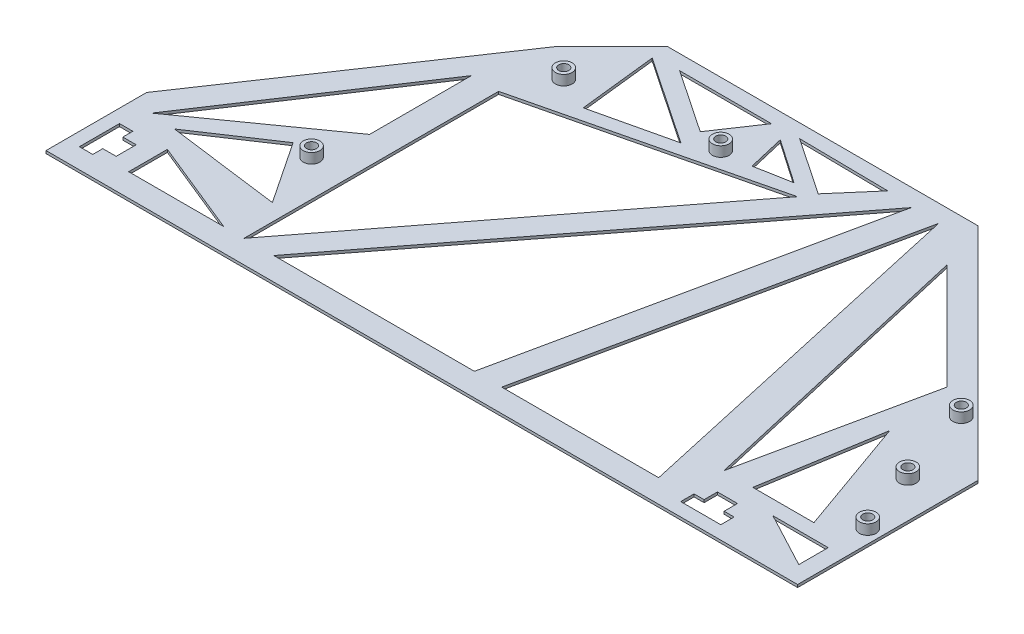
from build123d import *

# Parameters (mm, degrees)
SKETCH2_R                 = 2.5
BOSS_EXTRUDE1_DEPTH       = 3
BOSS_EXTRUDE1_2_DEPTH     = 3
BOSS_EXTRUDE1_3_DEPTH     = 3
BOSS_EXTRUDE1_4_DEPTH     = 3
BOSS_EXTRUDE1_5_DEPTH     = 3
BOSS_EXTRUDE1_6_DEPTH     = 3
SKETCH4_W                 = 225
SKETCH4_H                 = 120
BOSS_EXTRUDE2_DEPTH       = 0.8
F_3_0MM_DOWEL_HOLE1_D     = 3
F_3_0MM_DOWEL_HOLE1_DEPTH = 4
CUT_EXTRUDE1_REACH        = 2.8
CHAMFER1_SIZE             = 66
CUT_EXTRUDE2_REACH        = 2.8
CHAMFER3_SIZE             = 70
CHAMFER3_SIZE2            = 23.885549322


with BuildPart() as part:
    # Sketch2 → Boss-Extrude1 (new body)
    with BuildSketch(Plane(origin=(0, 0, 0), x_dir=(1, 0, 0), z_dir=(0, 1, 0))):
        with Locations((101, 101)):
            Circle(SKETCH2_R)
    extrude(amount=BOSS_EXTRUDE1_DEPTH)



with BuildPart() as body_2:
    # Sketch2 → Boss-Extrude1 2 (new body)
    with BuildSketch(Plane(origin=(0, 0, 0), x_dir=(1, 0, 0), z_dir=(0, 1, 0))):
        with Locations((206, 68)):
            Circle(SKETCH2_R)
    extrude(amount=BOSS_EXTRUDE1_2_DEPTH)


with BuildPart() as body_3:
    # Sketch2 → Boss-Extrude1 3 (new body)
    with BuildSketch(Plane(origin=(0, 0, 0), x_dir=(1, 0, 0), z_dir=(0, 1, 0))):
        with Locations((214, 44)):
            Circle(SKETCH2_R)
    extrude(amount=BOSS_EXTRUDE1_3_DEPTH)


with BuildPart() as body_4:
    # Sketch2 → Boss-Extrude1 4 (new body)
    with BuildSketch(Plane(origin=(0, 0, 0), x_dir=(1, 0, 0), z_dir=(0, 1, 0))):
        with Locations((221, 25)):
            Circle(SKETCH2_R)
    extrude(amount=BOSS_EXTRUDE1_4_DEPTH)


with BuildPart() as body_5:
    # Sketch2 → Boss-Extrude1 5 (new body)
    with BuildSketch(Plane(origin=(0, 0, 0), x_dir=(1, 0, 0), z_dir=(0, 1, 0))):
        with Locations((41.5, 38)):
            Circle(SKETCH2_R)
    extrude(amount=BOSS_EXTRUDE1_5_DEPTH)


with BuildPart() as body_6:
    # Sketch2 → Boss-Extrude1 6 (new body)
    with BuildSketch(Plane(origin=(0, 0, 0), x_dir=(1, 0, 0), z_dir=(0, 1, 0))):
        with Locations((59, 96)):
            Circle(SKETCH2_R)
    extrude(amount=BOSS_EXTRUDE1_6_DEPTH)


with BuildPart() as part_1:
    add(part.part)

    add(body_2.part)  # Boss-Extrude2 merges body 2

    add(body_3.part)  # Boss-Extrude2 merges body 3

    add(body_4.part)  # Boss-Extrude2 merges body 4

    add(body_5.part)  # Boss-Extrude2 merges body 5

    add(body_6.part)  # Boss-Extrude2 merges body 6
    # Sketch4 → Boss-Extrude2 (add)
    with BuildSketch(Plane(origin=(0, 0, 0), x_dir=(1, 0, 0), z_dir=(0, 1, 0))):
        with Locations((112.5, 60)):
            Rectangle(SKETCH4_W, SKETCH4_H)
    extrude(amount=-BOSS_EXTRUDE2_DEPTH)

    # Ø3.0mm Dowel Hole1
    with Locations(Plane(origin=(0, 3, 0), x_dir=(1, 0, 0), z_dir=(0, 1, 0))):
        with Locations((59, 96), (101, 101), (206, 68), (214, 44), (221, 25), (41.5, 38)):
            Hole(F_3_0MM_DOWEL_HOLE1_D / 2, depth=F_3_0MM_DOWEL_HOLE1_DEPTH)

    # Sketch27 → Cut-Extrude1 (cut, up to next)
    with BuildSketch(Plane(origin=(0, 0, 0), x_dir=(1, 0, 0), z_dir=(0, 1, 0)), mode=Mode.PRIVATE) as cut_extrude1_sk1:
        Polygon((186, 8), (189, 8), (189, 12), (195, 12), (195, 8), (198, 8), (198, 4), (186, 4), align=None)
    cut_extrude1_tool1 = extrude(cut_extrude1_sk1.sketch, amount=-CUT_EXTRUDE1_REACH, mode=Mode.PRIVATE) & part_1.part
    add(cut_extrude1_tool1.solids().sort_by_distance((192, 0, -7.333333))[0], mode=Mode.SUBTRACT)
    # Sketch27 → Cut-Extrude1 (cut, up to next)
    with BuildSketch(Plane(origin=(0, 0, 0), x_dir=(1, 0, 0), z_dir=(0, 1, 0)), mode=Mode.PRIVATE) as cut_extrude1_sk2:
        Polygon((4, 6), (8, 6), (8, 9), (12, 9), (12, 15), (8, 15), (8, 18), (4, 18), align=None)
    cut_extrude1_tool2 = extrude(cut_extrude1_sk2.sketch, amount=-CUT_EXTRUDE1_REACH, mode=Mode.PRIVATE) & part_1.part
    add(cut_extrude1_tool2.solids().sort_by_distance((7.333333, 0, -12))[0], mode=Mode.SUBTRACT)

    # Chamfer1
    chamfer1_edges = [part_1.edges().sort_by_distance(p)[0] for p in [
        (0, -0.4, -120),
        (225, -0.4, -120),
    ]]
    chamfer(chamfer1_edges, length=CHAMFER1_SIZE)

    # Sketch28 → Cut-Extrude2 (cut, up to next)
    with BuildSketch(Plane(origin=(0, 0, 0), x_dir=(1, 0, 0), z_dir=(0, 1, 0)), mode=Mode.PRIVATE) as cut_extrude2_sk1:
        Polygon((52.388319297, 6.891877983), (52.388319297, 83.093591857), (124.427979621, 100.514856146), align=None)
    cut_extrude2_tool1 = extrude(cut_extrude2_sk1.sketch, amount=-CUT_EXTRUDE2_REACH, mode=Mode.PRIVATE) & part_1.part
    add(cut_extrude2_tool1.solids().sort_by_distance((76.401539, 0, -63.500109))[0], mode=Mode.SUBTRACT)
    # Sketch28 → Cut-Extrude2 (cut, up to next)
    with BuildSketch(Plane(origin=(0, 0, 0), x_dir=(1, 0, 0), z_dir=(0, 1, 0)), mode=Mode.PRIVATE) as cut_extrude2_sk2:
        Polygon((144.286671327, 114.724380441), (61.313270979, 6.891877983), (121.338711512, 6.891877983), align=None)
    cut_extrude2_tool2 = extrude(cut_extrude2_sk2.sketch, amount=-CUT_EXTRUDE2_REACH, mode=Mode.PRIVATE) & part_1.part
    add(cut_extrude2_tool2.solids().sort_by_distance((108.979551, 0, -42.836045))[0], mode=Mode.SUBTRACT)
    # Sketch28 → Cut-Extrude2 (cut, up to next)
    with BuildSketch(Plane(origin=(0, 0, 0), x_dir=(1, 0, 0), z_dir=(0, 1, 0)), mode=Mode.PRIVATE) as cut_extrude2_sk3:
        Polygon((152.485832321, 114.724380441), (129.537872506, 6.891877983), (176.515283586, 6.891877983), align=None)
    cut_extrude2_tool3 = extrude(cut_extrude2_sk3.sketch, amount=-CUT_EXTRUDE2_REACH, mode=Mode.PRIVATE) & part_1.part
    add(cut_extrude2_tool3.solids().sort_by_distance((152.846329, 0, -42.836045))[0], mode=Mode.SUBTRACT)
    # Sketch28 → Cut-Extrude2 (cut, up to next)
    with BuildSketch(Plane(origin=(0, 0, 0), x_dir=(1, 0, 0), z_dir=(0, 1, 0)), mode=Mode.PRIVATE) as cut_extrude2_sk4:
        Polygon((164.500557953, 105.19569086), (196.171947419, 73.524301395), (184.457582932, 18.478482617), align=None)
    cut_extrude2_tool4 = extrude(cut_extrude2_sk4.sketch, amount=-CUT_EXTRUDE2_REACH, mode=Mode.PRIVATE) & part_1.part
    add(cut_extrude2_tool4.solids().sort_by_distance((181.710029, 0, -65.732825))[0], mode=Mode.SUBTRACT)
    # Sketch28 → Cut-Extrude2 (cut, up to next)
    with BuildSketch(Plane(origin=(0, 0, 0), x_dir=(1, 0, 0), z_dir=(0, 1, 0)), mode=Mode.PRIVATE) as cut_extrude2_sk5:
        Polygon((198.888278472, 53.703367065), (211.405882256, 18.478482617), (193.110922879, 18.478482617), align=None)
    cut_extrude2_tool5 = extrude(cut_extrude2_sk5.sketch, amount=-CUT_EXTRUDE2_REACH, mode=Mode.PRIVATE) & part_1.part
    add(cut_extrude2_tool5.solids().sort_by_distance((201.135028, 0, -30.220111))[0], mode=Mode.SUBTRACT)
    # Sketch28 → Cut-Extrude2 (cut, up to next)
    with BuildSketch(Plane(origin=(0, 0, 0), x_dir=(1, 0, 0), z_dir=(0, 1, 0)), mode=Mode.PRIVATE) as cut_extrude2_sk6:
        Polygon((44.242680865, 83.093591857), (44.242680865, 52.616095827), (6.082421341, 25.506148765), align=None)
    cut_extrude2_tool6 = extrude(cut_extrude2_sk6.sketch, amount=-CUT_EXTRUDE2_REACH, mode=Mode.PRIVATE) & part_1.part
    add(cut_extrude2_tool6.solids().sort_by_distance((31.522594, 0, -53.738612))[0], mode=Mode.SUBTRACT)
    # Sketch28 → Cut-Extrude2 (cut, up to next)
    with BuildSketch(Plane(origin=(0, 0, 0), x_dir=(1, 0, 0), z_dir=(0, 1, 0)), mode=Mode.PRIVATE) as cut_extrude2_sk7:
        Polygon((13.630560586, 24.81954669), (34.944244067, 39.030171699), (47.359604213, 20.409100754), align=None)
    cut_extrude2_tool7 = extrude(cut_extrude2_sk7.sketch, amount=-CUT_EXTRUDE2_REACH, mode=Mode.PRIVATE) & part_1.part
    add(cut_extrude2_tool7.solids().sort_by_distance((31.978136, 0, -28.086273))[0], mode=Mode.SUBTRACT)
    # Sketch28 → Cut-Extrude2 (cut, up to next)
    with BuildSketch(Plane(origin=(0, 0, 0), x_dir=(1, 0, 0), z_dir=(0, 1, 0)), mode=Mode.PRIVATE) as cut_extrude2_sk8:
        Polygon((17.858383702, 18.478482617), (17.858383702, 6.891877983), (46.339021234, 6.891877983), align=None)
    cut_extrude2_tool8 = extrude(cut_extrude2_sk8.sketch, amount=-CUT_EXTRUDE2_REACH, mode=Mode.PRIVATE) & part_1.part
    add(cut_extrude2_tool8.solids().sort_by_distance((27.35193, 0, -10.75408))[0], mode=Mode.SUBTRACT)
    # Sketch28 → Cut-Extrude2 (cut, up to next)
    with BuildSketch(Plane(origin=(0, 0, 0), x_dir=(1, 0, 0), z_dir=(0, 1, 0)), mode=Mode.PRIVATE) as cut_extrude2_sk9:
        Polygon((66.741601703, 114.724380441), (69.339310273, 91.487471585), (93.043400976, 97.007602296), align=None)
    cut_extrude2_tool9 = extrude(cut_extrude2_sk9.sketch, amount=-CUT_EXTRUDE2_REACH, mode=Mode.PRIVATE) & part_1.part
    add(cut_extrude2_tool9.solids().sort_by_distance((76.374771, 0, -101.073151))[0], mode=Mode.SUBTRACT)
    # Sketch28 → Cut-Extrude2 (cut, up to next)
    with BuildSketch(Plane(origin=(0, 0, 0), x_dir=(1, 0, 0), z_dir=(0, 1, 0)), mode=Mode.PRIVATE) as cut_extrude2_sk10:
        Polygon((74.134214928, 115.550818021), (93.043400976, 102.813672146), (101.623087305, 115.550818021), align=None)
    cut_extrude2_tool10 = extrude(cut_extrude2_sk10.sketch, amount=-CUT_EXTRUDE2_REACH, mode=Mode.PRIVATE) & part_1.part
    add(cut_extrude2_tool10.solids().sort_by_distance((89.600234, 0, -111.305103))[0], mode=Mode.SUBTRACT)
    # Sketch28 → Cut-Extrude2 (cut, up to next)
    with BuildSketch(Plane(origin=(0, 0, 0), x_dir=(1, 0, 0), z_dir=(0, 1, 0)), mode=Mode.PRIVATE) as cut_extrude2_sk11:
        Polygon((136.446781668, 115.550818021), (126.813612387, 104.367776578), (109.710747348, 115.88819244), align=None)
    cut_extrude2_tool11 = extrude(cut_extrude2_sk11.sketch, amount=-CUT_EXTRUDE2_REACH, mode=Mode.PRIVATE) & part_1.part
    add(cut_extrude2_tool11.solids().sort_by_distance((124.323714, 0, -111.935596))[0], mode=Mode.SUBTRACT)
    # Sketch28 → Cut-Extrude2 (cut, up to next)
    with BuildSketch(Plane(origin=(0, 0, 0), x_dir=(1, 0, 0), z_dir=(0, 1, 0)), mode=Mode.PRIVATE) as cut_extrude2_sk12:
        Polygon((107.114322397, 112.702091574), (120.319340962, 103.610111579), (109.710747348, 101.653186543), align=None)
    cut_extrude2_tool12 = extrude(cut_extrude2_sk12.sketch, amount=-CUT_EXTRUDE2_REACH, mode=Mode.PRIVATE) & part_1.part
    add(cut_extrude2_tool12.solids().sort_by_distance((112.38147, 0, -105.988463))[0], mode=Mode.SUBTRACT)
    # Sketch28 → Cut-Extrude2 (cut, up to next)
    with BuildSketch(Plane(origin=(0, 0, 0), x_dir=(1, 0, 0), z_dir=(0, 1, 0)), mode=Mode.PRIVATE) as cut_extrude2_sk13:
        Polygon((203.456645773, 14.141546381), (220.018577109, 14.141546381), (220.018577109, 5.336468962), align=None)
    cut_extrude2_tool13 = extrude(cut_extrude2_sk13.sketch, amount=-CUT_EXTRUDE2_REACH, mode=Mode.PRIVATE) & part_1.part
    add(cut_extrude2_tool13.solids().sort_by_distance((214.497933, 0, -11.206521))[0], mode=Mode.SUBTRACT)

    # Chamfer3
    chamfer3_edges = [part_1.edges().sort_by_distance(p)[0] for p in [
        (0, -0.4, -54),
    ]]
    chamfer3_side = [part_1.faces().sort_by_distance(p)[0] for p in [
        (33, -0.4, -87),
    ]]
    chamfer(chamfer3_edges, length=CHAMFER3_SIZE, length2=CHAMFER3_SIZE2, reference=chamfer3_side[0])


solid = part_1.part
